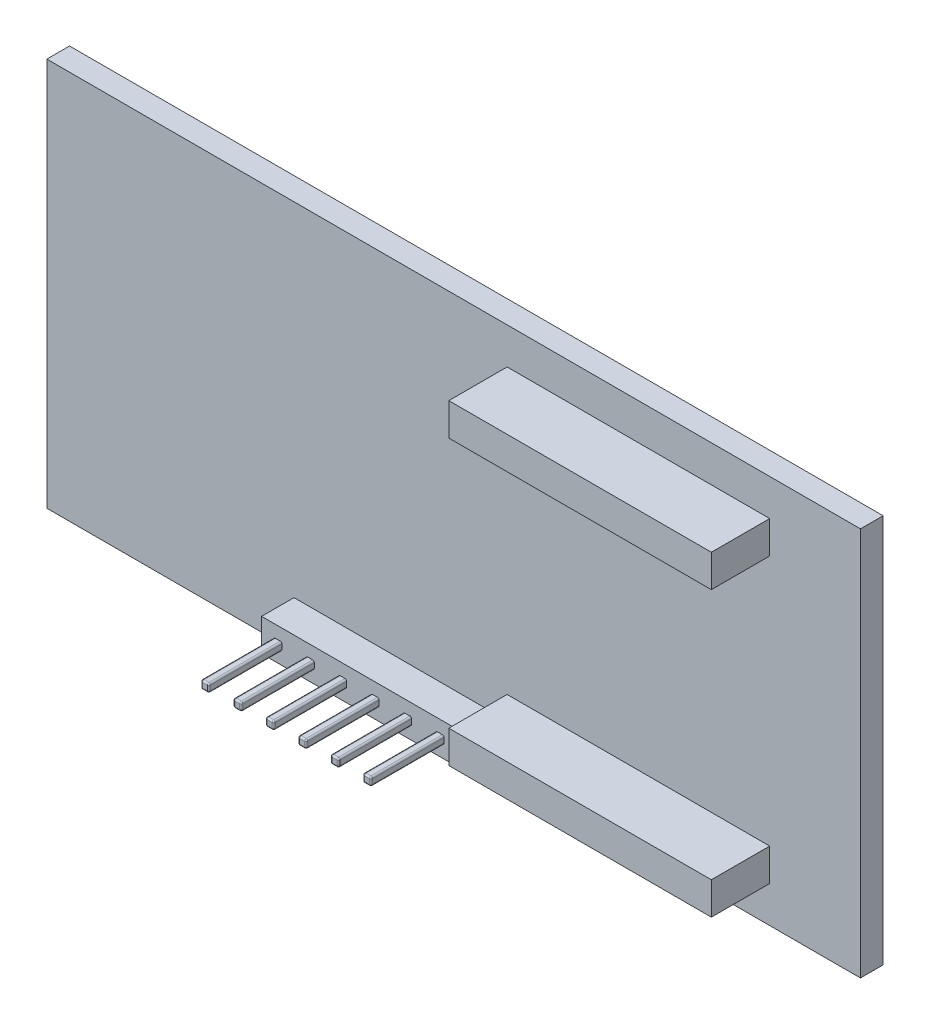
from build123d import *

# Parameters (mm, degrees)
SKETCH1_W              = 63.754
SKETCH1_H              = 30.48
BOSS_EXTRUDE1_DEPTH    = 0.889
SKETCH2_W              = 20.574
SKETCH2_H              = 2.54
BOSS_EXTRUDE2_DEPTH    = 4.572
SKETCH3_W              = 0.635
SKETCH3_H              = 0.635
BOSS_EXTRUDE3_DEPTH    = 8.255
FILLET3_R              = 0.127
FILLET4_R              = 0.127
LPATTERN1_COUNT        = 6
LPATTERN1_PITCH        = 2.54
FILLET3_OF_LPATTERN1_R = 0.127
FILLET4_OF_LPATTERN1_R = 0.127
SKETCH4_W              = 15.24
SKETCH4_H              = 2.54
BOSS_EXTRUDE4_DEPTH    = 2.54


with BuildPart() as part:
    # Sketch1 → Boss-Extrude1 (new body, symmetric)
    with BuildSketch(Plane.XY):
        Rectangle(SKETCH1_W, SKETCH1_H)
    extrude(amount=BOSS_EXTRUDE1_DEPTH, both=True)

    # Sketch2 → Boss-Extrude2 (add)
    with BuildSketch(Plane.XY.offset(0.889)):
        with Locations((14.478, 11.1125)):
            Rectangle(SKETCH2_W, SKETCH2_H)
    boss_extrude2 = extrude(amount=BOSS_EXTRUDE2_DEPTH)

    # Mirror1: Boss-Extrude2 across plane
    add(boss_extrude2.mirror(Plane.ZX))

    # Sketch3 → Boss-Extrude3 (add)
    with BuildSketch(Plane.XY.offset(0.889)):
        with Locations((-11.2395, -12.8905)):
            Rectangle(SKETCH3_W, SKETCH3_H)
    boss_extrude3 = extrude(amount=BOSS_EXTRUDE3_DEPTH)

    # Fillet3
    fillet3_edges = [part.edges().sort_by_distance(p)[0] for p in [
        (-10.922, -13.208, 5.0165),
        (-10.922, -12.573, 5.0165),
        (-11.557, -12.573, 5.0165),
        (-11.557, -13.208, 5.0165),
    ]]
    fillet(fillet3_edges, radius=FILLET3_R)

    # Fillet4
    fillet4_edges = [part.edges().sort_by_distance(p)[0] for p in [
        (-10.922, -12.8905, 9.144),
        (-11.2395, -13.208, 9.144),
        (-11.2395, -12.573, 9.144),
        (-11.557, -12.8905, 9.144),
        (-11.519802561, -12.610197439, 9.144),
        (-10.959197439, -12.610197439, 9.144),
        (-11.519802561, -13.170802561, 9.144),
        (-10.959197439, -13.170802561, 9.144),
    ]]
    fillet(fillet4_edges, radius=FILLET4_R)

    # LPattern1: Boss-Extrude3 ×6
    with Locations(*[(i * LPATTERN1_PITCH, 0, 0) for i in range(1, LPATTERN1_COUNT)]):
        add(boss_extrude3)

    # Fillet3 of LPattern1
    fillet3_of_lpattern1_edges = [part.edges().sort_by_distance(p)[0] for p in [
        (-8.382, -13.208, 5.0165),
        (-8.382, -12.573, 5.0165),
        (-9.017, -12.573, 5.0165),
        (-9.017, -13.208, 5.0165),
        (-5.842, -13.208, 5.0165),
        (-5.842, -12.573, 5.0165),
        (-6.477, -12.573, 5.0165),
        (-6.477, -13.208, 5.0165),
        (-3.302, -13.208, 5.0165),
        (-3.302, -12.573, 5.0165),
        (-3.937, -12.573, 5.0165),
        (-3.937, -13.208, 5.0165),
        (-0.762, -13.208, 5.0165),
        (-0.762, -12.573, 5.0165),
        (-1.397, -12.573, 5.0165),
        (-1.397, -13.208, 5.0165),
        (1.778, -13.208, 5.0165),
        (1.778, -12.573, 5.0165),
        (1.143, -12.573, 5.0165),
        (1.143, -13.208, 5.0165),
    ]]
    fillet(fillet3_of_lpattern1_edges, radius=FILLET3_OF_LPATTERN1_R)

    # Fillet4 of LPattern1
    fillet4_of_lpattern1_edges = [part.edges().sort_by_distance(p)[0] for p in [
        (-8.382, -12.8905, 9.144),
        (-8.6995, -13.208, 9.144),
        (-8.6995, -12.573, 9.144),
        (-9.017, -12.8905, 9.144),
        (-8.979802561, -12.610197439, 9.144),
        (-8.419197439, -12.610197439, 9.144),
        (-8.979802561, -13.170802561, 9.144),
        (-8.419197439, -13.170802561, 9.144),
        (-5.842, -12.8905, 9.144),
        (-6.1595, -13.208, 9.144),
        (-6.1595, -12.573, 9.144),
        (-6.477, -12.8905, 9.144),
        (-6.439802561, -12.610197439, 9.144),
        (-5.879197439, -12.610197439, 9.144),
        (-6.439802561, -13.170802561, 9.144),
        (-5.879197439, -13.170802561, 9.144),
        (-3.302, -12.8905, 9.144),
        (-3.6195, -13.208, 9.144),
        (-3.6195, -12.573, 9.144),
        (-3.937, -12.8905, 9.144),
        (-3.899802561, -12.610197439, 9.144),
        (-3.339197439, -12.610197439, 9.144),
        (-3.899802561, -13.170802561, 9.144),
        (-3.339197439, -13.170802561, 9.144),
        (-0.762, -12.8905, 9.144),
        (-1.0795, -13.208, 9.144),
        (-1.0795, -12.573, 9.144),
        (-1.397, -12.8905, 9.144),
        (-1.359802561, -12.610197439, 9.144),
        (-0.799197439, -12.610197439, 9.144),
        (-1.359802561, -13.170802561, 9.144),
        (-0.799197439, -13.170802561, 9.144),
        (1.778, -12.8905, 9.144),
        (1.4605, -13.208, 9.144),
        (1.4605, -12.573, 9.144),
        (1.143, -12.8905, 9.144),
        (1.180197439, -12.610197439, 9.144),
        (1.740802561, -12.610197439, 9.144),
        (1.180197439, -13.170802561, 9.144),
        (1.740802561, -13.170802561, 9.144),
    ]]
    fillet(fillet4_of_lpattern1_edges, radius=FILLET4_OF_LPATTERN1_R)

    # Sketch4 → Boss-Extrude4 (add)
    with BuildSketch(Plane.XY.offset(0.889)):
        with Locations((-4.8895, -12.8905)):
            Rectangle(SKETCH4_W, SKETCH4_H)
    extrude(amount=BOSS_EXTRUDE4_DEPTH)


solid = part.part
